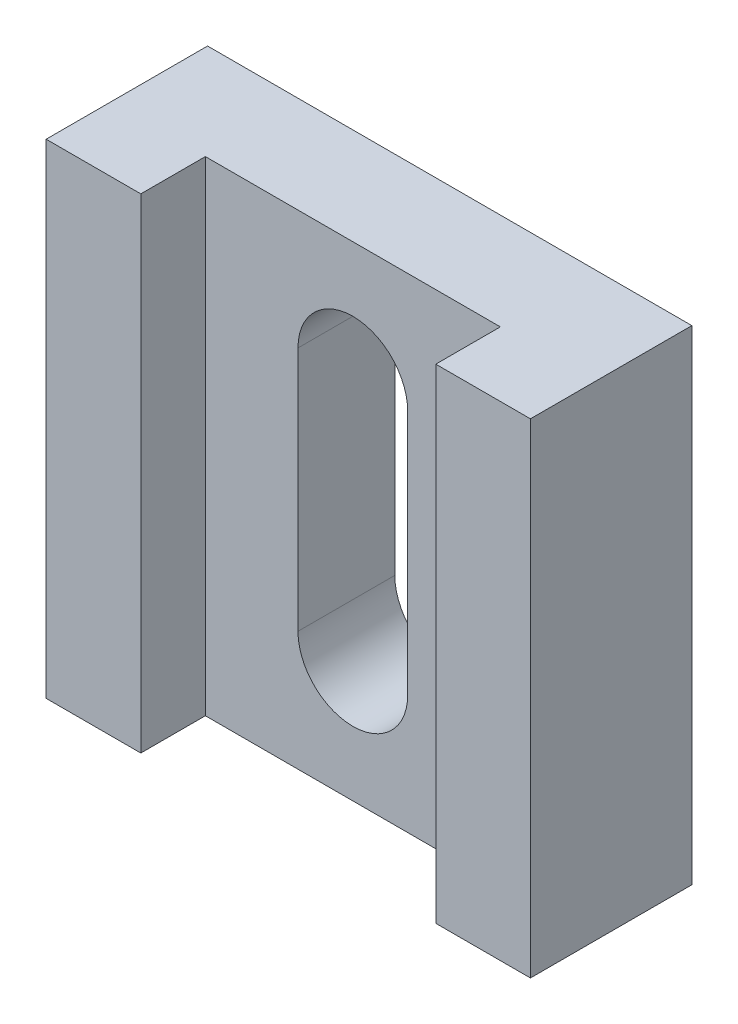
from build123d import *

# Parameters (mm, degrees)
SKETCH1_W           = 15
SKETCH1_H           = 15
BOSS_EXTRUDE1_DEPTH = 5
SKETCH2_W           = 9.136161194
SKETCH2_H           = 15
CUT_EXTRUDE1_DEPTH  = 2
CUT_EXTRUDE2_DEPTH  = 12


with BuildPart() as part:
    # Sketch1 → Boss-Extrude1 (new body)
    with BuildSketch(Plane.XY):
        Rectangle(SKETCH1_W, SKETCH1_H)
    extrude(amount=BOSS_EXTRUDE1_DEPTH)

    # Sketch2 → Cut-Extrude1 (cut)
    with BuildSketch(Plane.XY.offset(5)):
        Rectangle(SKETCH2_W, SKETCH2_H)
    extrude(amount=-CUT_EXTRUDE1_DEPTH, mode=Mode.SUBTRACT)

    # Sketch3 → Cut-Extrude2 (cut)
    with BuildSketch(Plane.XY.offset(3)):
        with BuildLine():
            Line((-1.7, 3.8), (-1.7, -3.8))
            ThreePointArc((-1.7, -3.8), (0, -5.5), (1.7, -3.8))
            Line((1.7, -3.8), (1.7, 3.8))
            ThreePointArc((1.7, 3.8), (0, 5.5), (-1.7, 3.8))
        make_face()
    extrude(amount=-CUT_EXTRUDE2_DEPTH, mode=Mode.SUBTRACT)


solid = part.part
